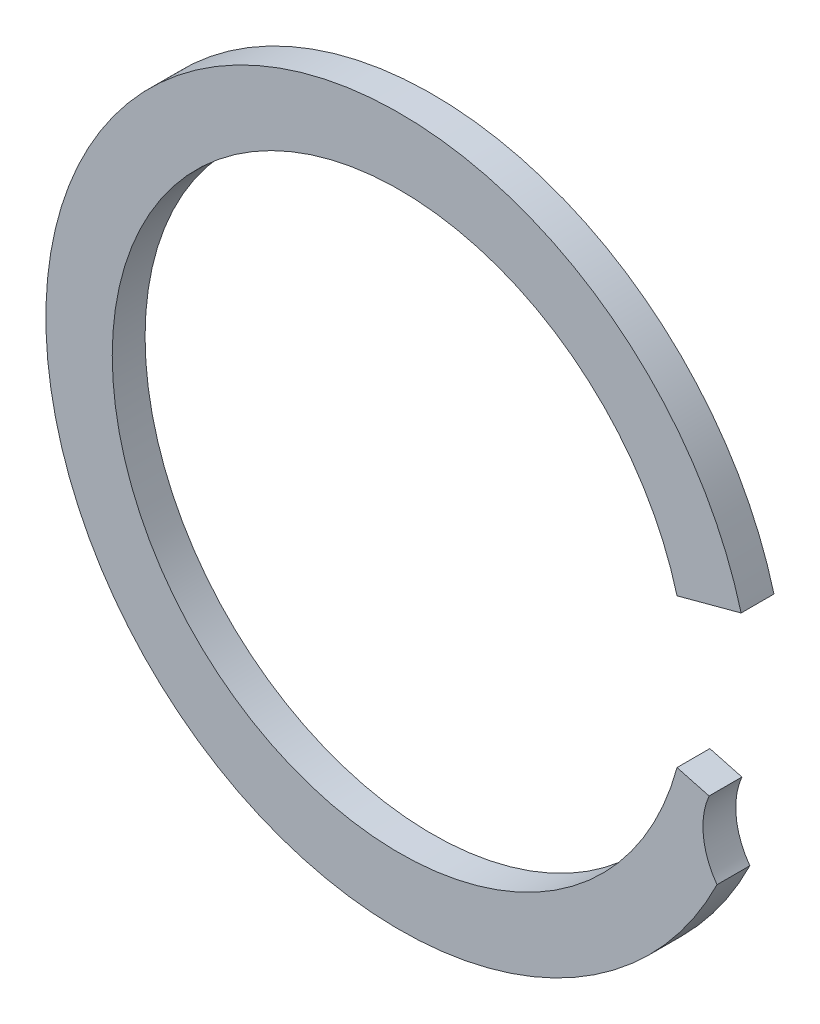
from build123d import *

# Parameters (mm, degrees)
BOSS_EXTRUDE1_DEPTH = 0.94


with BuildPart() as part:
    # Sketch2 → Boss-Extrude1 (new body)
    with BuildSketch(Plane.XY):
        with BuildLine():
            Line((7.944739921, 2.128786646), (8.862369456, 2.374664739))
            Line((8.862369456, 2.374664739), (9.779998991, 2.620542832))
            ThreePointArc((9.779998991, 2.620542832), (-10.077153498, 0.983159385), (9.089055299, -4.46146823))
            ThreePointArc((9.089055299, -4.46146823), (8.698265252, -3.448205084), (8.862369456, -2.374664739))
            Line((8.862369456, -2.374664739), (7.944739921, -2.128786646))
            ThreePointArc((7.944739921, -2.128786646), (-8.225, 0), (7.944739921, 2.128786646))
        make_face()
    extrude(amount=BOSS_EXTRUDE1_DEPTH)


solid = part.part
